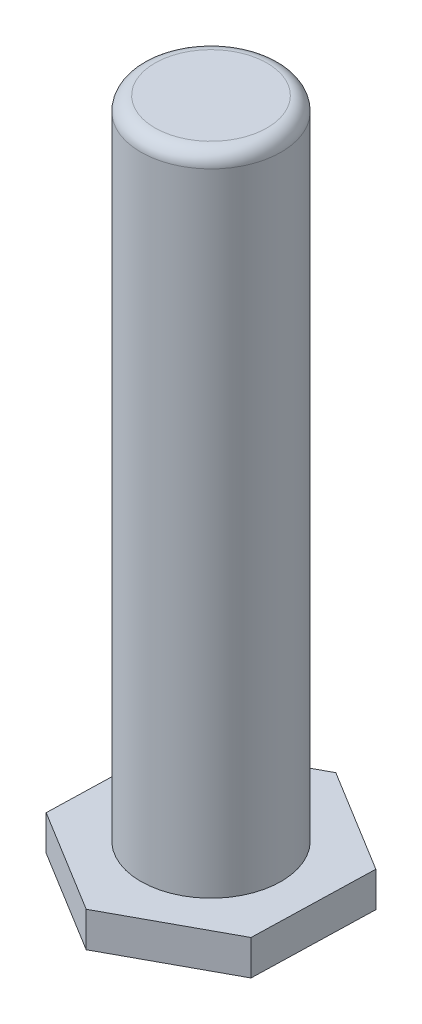
from build123d import *

# Parameters (mm, degrees)
BOSS_EXTRU_1_DEPTH = 5
ESQUISSE2_R        = 10
BOSS_EXTRU_2_DEPTH = 92
CONG_1_R           = 2


with BuildPart() as part:
    # Esquisse1 → Boss.-Extru.1 (new body)
    with BuildSketch(Plane(origin=(0, 0, 0), x_dir=(1, 0, 0), z_dir=(0, 1, 0))):
        Polygon((-14.767960782, 9.062157753), (-15.232039218, -8.258350323), (-0.464078436, -17.320508076), (14.767960782, -9.062157753), (15.232039218, 8.258350323), (0.464078436, 17.320508076), align=None)
    extrude(amount=BOSS_EXTRU_1_DEPTH)

    # Esquisse2 → Boss.-Extru.2 (add)
    with BuildSketch(Plane(origin=(0, 5, 0), x_dir=(1, 0, 0), z_dir=(0, 1, 0))):
        Circle(ESQUISSE2_R)
    extrude(amount=BOSS_EXTRU_2_DEPTH)

    # Congé1
    cong_1_edges = [part.edges().sort_by_distance(p)[0] for p in [
        (-10, 97, 0),
    ]]
    fillet(cong_1_edges, radius=CONG_1_R)


solid = part.part
